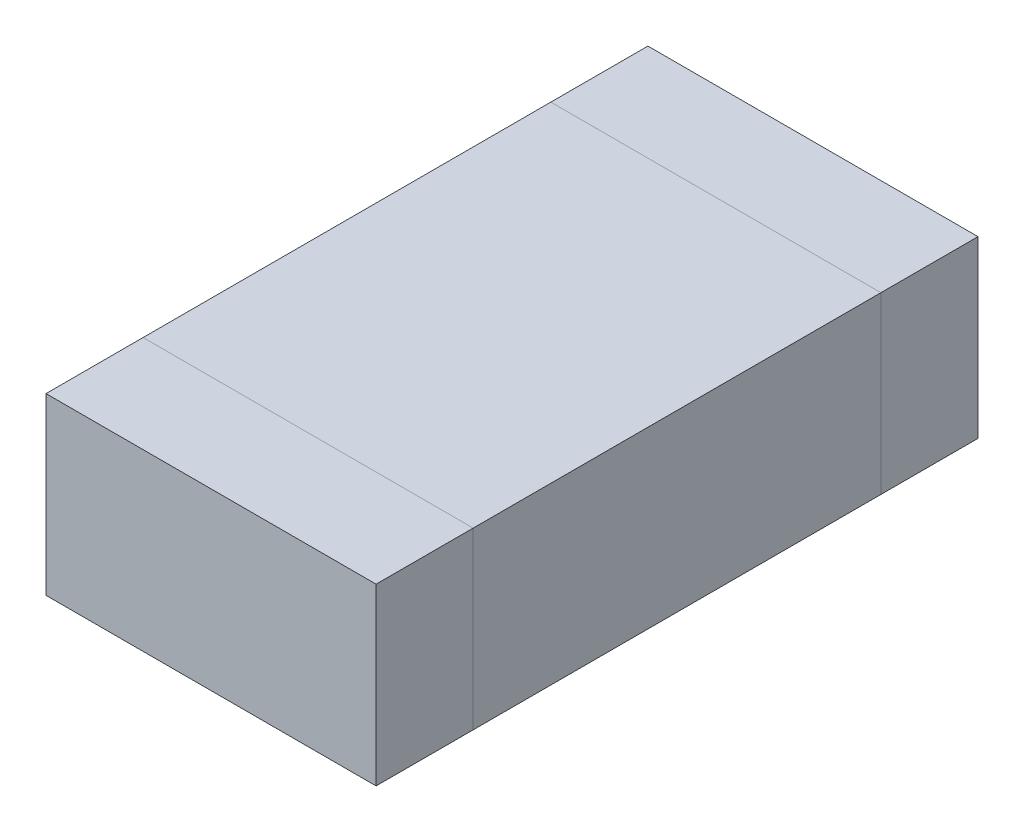
from build123d import *

# Parameters (mm, degrees)
MAINBODYS_W     = 0.85
MAINBODYS_H     = 1.05
MAINBODY_DEPTH  = 0.45
LEFTBODYS_W     = 0.85
LEFTBODYS_H     = 0.25
LEFTBODY_DEPTH  = 0.45
RIGHTBODYS_W    = 0.85
RIGHTBODYS_H    = 0.25
RIGHTBODY_DEPTH = 0.45


with BuildPart() as part:
    # MainBodyS → MainBody (new body)
    with BuildSketch(Plane(origin=(0, 0, 0), x_dir=(1, 0, 0), z_dir=(0, 1, 0))):
        Rectangle(MAINBODYS_W, MAINBODYS_H)
    extrude(amount=MAINBODY_DEPTH)


with BuildPart() as body_2:
    # LeftBodyS → LeftBody (new body)
    with BuildSketch(Plane(origin=(0, 0, 0), x_dir=(-1, 0, 0), z_dir=(0, -1, 0))):
        with Locations((0, -0.65)):
            Rectangle(LEFTBODYS_W, LEFTBODYS_H)
    extrude(amount=-LEFTBODY_DEPTH)


with BuildPart() as body_3:
    # RightBodyS → RightBody (new body)
    with BuildSketch(Plane.XZ):
        with Locations((0, -0.65)):
            Rectangle(RIGHTBODYS_W, RIGHTBODYS_H)
    extrude(amount=-RIGHTBODY_DEPTH)


solid = Compound([part.part, body_2.part, body_3.part])
